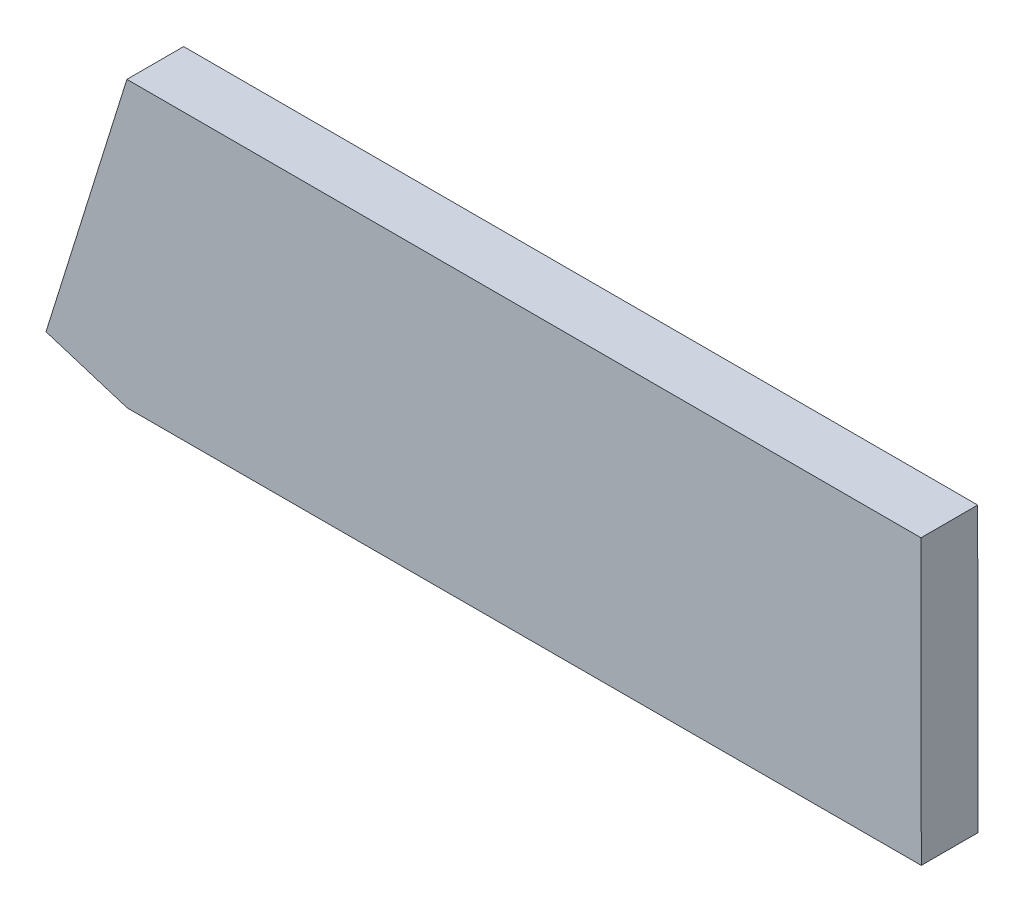
from build123d import *

# Parameters (mm, degrees)
BOSS_EXTRUDE1_DEPTH = 6.35


with BuildPart() as part:
    # Sketch1 → Boss-Extrude1 (new body)
    with BuildSketch(Plane.XY):
        Polygon((-44.45, 15.89843786), (44.45, 15.89843786), (44.483470038, -15.851544498), (-44.416480565, -15.945260604), (-53.508385872, -13.105739009), align=None)
    extrude(amount=BOSS_EXTRUDE1_DEPTH)


solid = part.part
